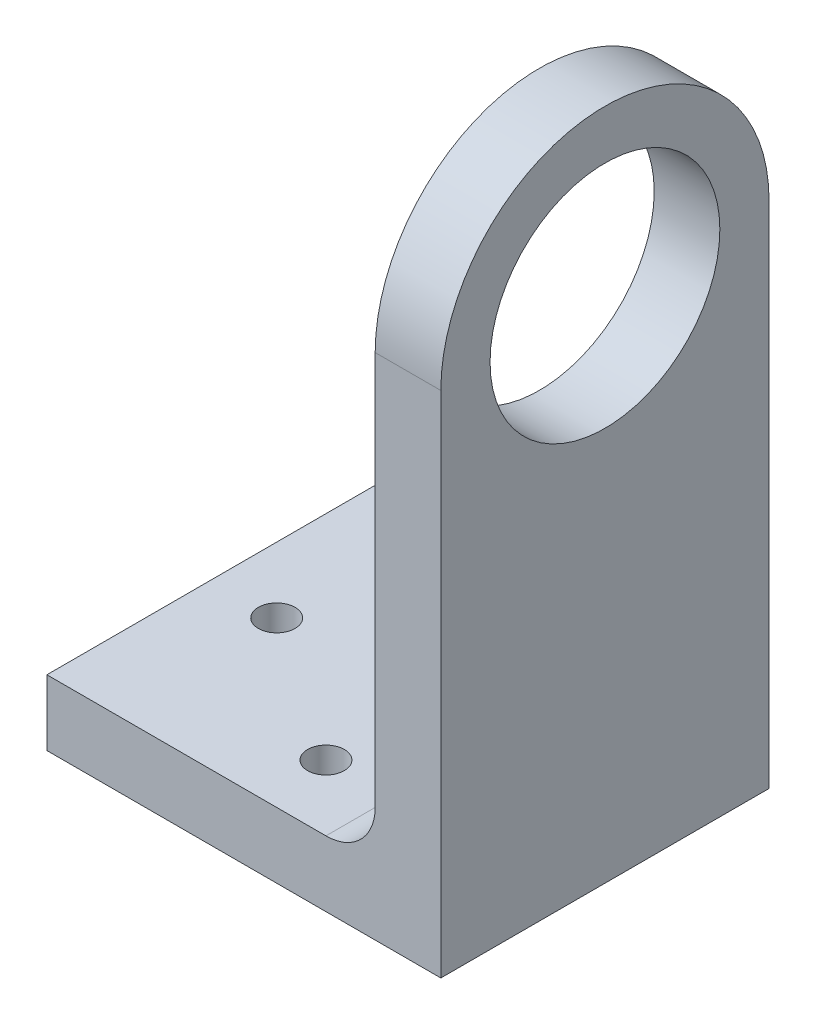
from build123d import *

# Parameters (mm, degrees)
SKETCH3_R           = 11.1125
BOSS_EXTRUDE1_DEPTH = 6.35
SKETCH5_W           = 31.75
SKETCH5_H           = 6.35
BOSS_EXTRUDE2_DEPTH = 38.1
FILLET1_R           = 4.7625
SKETCH6_R           = 1.777000002
CUT_EXTRUDE1_DEPTH  = 7.35


with BuildPart() as part:
    # Sketch3 → Boss-Extrude1 (new body)
    with BuildSketch(Plane(origin=(0, 0, 0), x_dir=(0, 0, -1), z_dir=(1, 0, 0))):
        with BuildLine():
            Line((0, 0), (31.75, 0))
            Line((31.75, 0), (31.75, 42.8625))
            ThreePointArc((31.75, 42.8625), (15.875, 58.7375), (0, 42.8625))
            Line((0, 42.8625), (0, 0))
        make_face()
        with Locations((15.875, 42.8625)):
            Circle(SKETCH3_R, mode=Mode.SUBTRACT)
    extrude(amount=BOSS_EXTRUDE1_DEPTH)

    # Sketch5 → Boss-Extrude2 (add)
    with BuildSketch(Plane(origin=(6.35, 0, 0), x_dir=(0, 0, -1), z_dir=(1, 0, 0))):
        with Locations((15.875, -3.175)):
            Rectangle(SKETCH5_W, SKETCH5_H)
    extrude(amount=-BOSS_EXTRUDE2_DEPTH)

    # Fillet1
    fillet1_edges = [part.edges().sort_by_distance(p)[0] for p in [
        (0, 0, -15.875),
    ]]
    fillet(fillet1_edges, radius=FILLET1_R)

    # Sketch6 → Cut-Extrude1 (cut, through all)
    with BuildSketch(Plane(origin=(0, 0, 0), x_dir=(1, 0, 0), z_dir=(0, 1, 0))):
        with Locations((-11.1125, 6.35)):
            Circle(SKETCH6_R)
        with Locations((-25.4, 15.875)):
            Circle(SKETCH6_R)
        with Locations((-11.1125, 25.4)):
            Circle(SKETCH6_R)
    extrude(amount=-CUT_EXTRUDE1_DEPTH, mode=Mode.SUBTRACT)


solid = part.part
